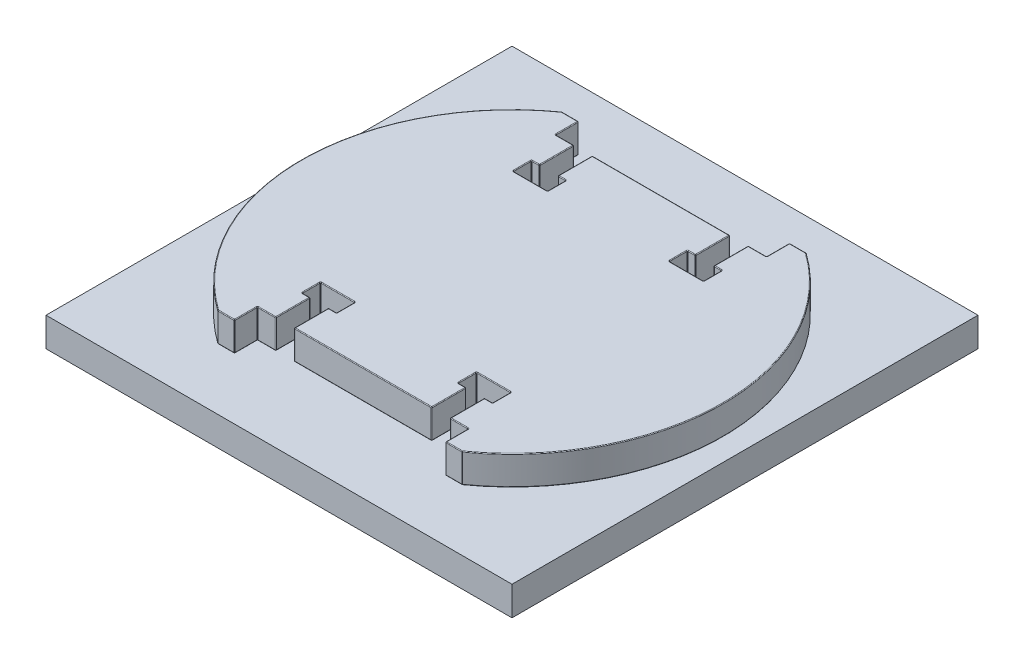
from build123d import *

# Parameters (mm, degrees)
BOSS_EXTRUDE1_DEPTH = 6.35
SKETCH2_W           = 4
SKETCH2_H           = 7.5
SKETCH2_W_2         = 7.5
SKETCH2_H_2         = 4
CUT_EXTRUDE1_DEPTH  = 7.35
FILLET1_R           = 0.15
SKETCH3_W           = 101.6
SKETCH3_H           = 101.6
BOSS_EXTRUDE2_DEPTH = 6.35


with BuildPart() as part:
    # Sketch1 → Boss-Extrude1 (new body)
    with BuildSketch(Plane(origin=(0, 0, 0), x_dir=(1, 0, 0), z_dir=(0, 1, 0))):
        with BuildLine():
            Line((-26.64113361, 37.5), (-23, 37.5))
            Line((-23, 37.5), (-23, 32.5))
            Line((-23, 32.5), (23, 32.5))
            Line((23, 32.5), (23, 37.5))
            Line((23, 37.5), (26.64113361, 37.5))
            ThreePointArc((26.64113361, 37.5), (46, 0), (26.64113361, -37.5))
            Line((26.64113361, -37.5), (23, -37.5))
            Line((23, -37.5), (23, -32.5))
            Line((23, -32.5), (-23, -32.5))
            Line((-23, -32.5), (-23, -37.5))
            Line((-23, -37.5), (-26.64113361, -37.5))
            ThreePointArc((-26.64113361, -37.5), (-46, 0), (-26.64113361, 37.5))
        make_face()
    extrude(amount=BOSS_EXTRUDE1_DEPTH)

    # Sketch2 → Cut-Extrude1 (cut, through all)
    with BuildSketch(Plane(origin=(0, 6.35, 0), x_dir=(1, 0, 0), z_dir=(0, 1, 0))):
        with Locations((-17, 28.75)):
            Rectangle(SKETCH2_W, SKETCH2_H)
        with Locations((-17, 23)):
            Rectangle(SKETCH2_W_2, SKETCH2_H_2)
        with Locations((17, 23)):
            Rectangle(SKETCH2_W_2, SKETCH2_H_2)
        with Locations((17, 28.75)):
            Rectangle(SKETCH2_W, SKETCH2_H)
        with Locations((17, -28.75)):
            Rectangle(SKETCH2_W, SKETCH2_H)
        with Locations((17, -23)):
            Rectangle(SKETCH2_W_2, SKETCH2_H_2)
        with Locations((-17, -23)):
            Rectangle(SKETCH2_W_2, SKETCH2_H_2)
        with Locations((-17, -28.75)):
            Rectangle(SKETCH2_W, SKETCH2_H)
    extrude(amount=-CUT_EXTRUDE1_DEPTH, mode=Mode.SUBTRACT)

    # Fillet1
    fillet1_edges = [part.edges().sort_by_distance(p)[0] for p in [
        (15, 6.35, -28.75),
        (15, 3.175, -25),
        (15, 3.175, -32.5),
        (19, 0, -28.75),
        (19, 3.175, -32.5),
        (19.875, 0, -25),
        (13.25, 0, -23),
        (14.125, 0, -25),
        (15, 0, -28.75),
        (17, 6.35, -21),
        (20.75, 6.35, -23),
        (19, 6.35, -28.75),
        (17, 0, -21),
        (20.75, 3.175, -21),
        (13.25, 6.35, -23),
        (13.25, 3.175, -21),
        (20.75, 0, -23),
        (20.75, 3.175, -25),
        (19, 3.175, -25),
        (19.875, 6.35, -25),
        (13.25, 3.175, -25),
        (14.125, 6.35, -25),
        (-21, 0, 32.5),
        (-23, 0, 35),
        (46, 6.35, 0),
        (-24.820566805, 0, 37.5),
        (-46, 0, 0),
        (-24.820566805, 0, -37.5),
        (-23, 0, -35),
        (21, 0, -32.5),
        (23, 0, -35),
        (24.820566805, 0, -37.5),
        (46, 0, 0),
        (24.820566805, 0, 37.5),
        (23, 0, 35),
        (24.820566805, 6.35, -37.5),
        (23, 3.175, 32.5),
        (-23, 3.175, 32.5),
        (-23, 3.175, 37.5),
        (23, 6.35, -35),
        (-26.64113361, 3.175, 37.5),
        (-26.64113361, 3.175, -37.5),
        (-23, 3.175, -37.5),
        (-23, 3.175, -32.5),
        (23, 3.175, -32.5),
        (23, 3.175, -37.5),
        (26.64113361, 3.175, -37.5),
        (26.64113361, 3.175, 37.5),
        (23, 3.175, 37.5),
        (21, 6.35, -32.5),
        (-23, 6.35, -35),
        (-24.820566805, 6.35, -37.5),
        (0, 0, 32.5),
        (21, 0, 32.5),
        (-46, 6.35, 0),
        (0, 0, -32.5),
        (-21, 0, -32.5),
        (-24.820566805, 6.35, 37.5),
        (-23, 6.35, 35),
        (-21, 6.35, 32.5),
        (23, 6.35, 35),
        (0, 6.35, -32.5),
        (-21, 6.35, -32.5),
        (0, 6.35, 32.5),
        (21, 6.35, 32.5),
        (-19, 6.35, -28.75),
        (-19, 3.175, -25),
        (-19, 3.175, -32.5),
        (-15, 0, -28.75),
        (-15, 3.175, -32.5),
        (-17, 0, -21),
        (-20.75, 0, -23),
        (-19, 0, -28.75),
        (-19.875, 6.35, -25),
        (-13.25, 6.35, -23),
        (-14.125, 6.35, -25),
        (-15, 6.35, -28.75),
        (-17, 6.35, -21),
        (-13.25, 3.175, -21),
        (-20.75, 6.35, -23),
        (-20.75, 3.175, -21),
        (-13.25, 0, -23),
        (-13.25, 3.175, -25),
        (-14.125, 0, -25),
        (-15, 3.175, -25),
        (-19.875, 0, -25),
        (-20.75, 3.175, -25),
        (17, 6.35, 21),
        (13.25, 3.175, 21),
        (20.75, 6.35, 23),
        (20.75, 3.175, 21),
        (13.25, 0, 23),
        (13.25, 3.175, 25),
        (13.25, 6.35, 23),
        (14.125, 6.35, 25),
        (15, 6.35, 28.75),
        (19.875, 6.35, 25),
        (17, 0, 21),
        (20.75, 0, 23),
        (19, 0, 28.75),
        (14.125, 0, 25),
        (15, 3.175, 25),
        (19.875, 0, 25),
        (20.75, 3.175, 25),
        (19, 3.175, 32.5),
        (15, 0, 28.75),
        (15, 3.175, 32.5),
        (19, 6.35, 28.75),
        (19, 3.175, 25),
        (24.820566805, 6.35, 37.5),
        (-15, 6.35, 28.75),
        (-15, 3.175, 25),
        (-15, 3.175, 32.5),
        (-19, 0, 28.75),
        (-19, 3.175, 32.5),
        (-19.875, 0, 25),
        (-13.25, 0, 23),
        (-14.125, 0, 25),
        (-15, 0, 28.75),
        (-17, 6.35, 21),
        (-20.75, 6.35, 23),
        (-19, 6.35, 28.75),
        (-17, 0, 21),
        (-20.75, 3.175, 21),
        (-13.25, 6.35, 23),
        (-13.25, 3.175, 21),
        (-20.75, 0, 23),
        (-20.75, 3.175, 25),
        (-19, 3.175, 25),
        (-19.875, 6.35, 25),
        (-13.25, 3.175, 25),
        (-14.125, 6.35, 25),
    ]]
    fillet(fillet1_edges, radius=FILLET1_R)

    # Sketch3 → Boss-Extrude2 (add)
    with BuildSketch(Plane.XZ):
        Rectangle(SKETCH3_W, SKETCH3_H)
    extrude(amount=BOSS_EXTRUDE2_DEPTH)


solid = part.part
